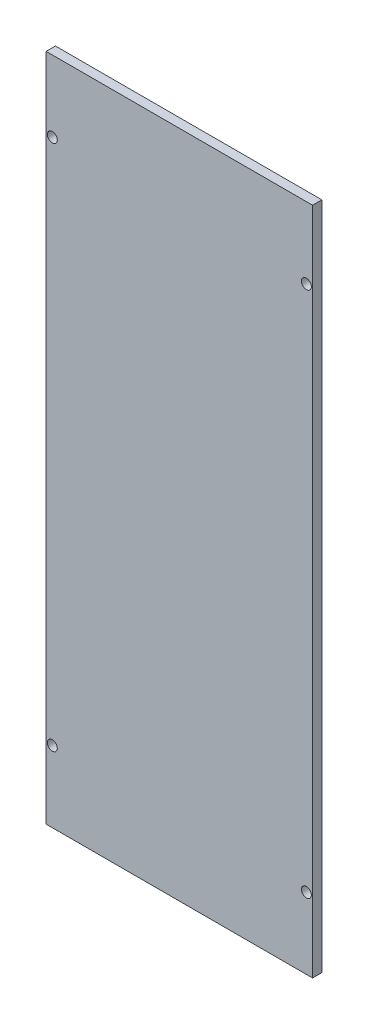
from build123d import *

# Parameters (mm, degrees)
SKETCH_1_W          = 86
SKETCH_1_H          = 216
EXTRUDE_1_DEPTH     = 3
SKETCH_2_R          = 1.6
CUT_EXTRUDE_1_DEPTH = 3


with BuildPart() as part:
    # 草图1 → 凸台-拉伸1 (new body)
    with BuildSketch(Plane.XY):
        with Locations((43, 108)):
            Rectangle(SKETCH_1_W, SKETCH_1_H)
    extrude(amount=EXTRUDE_1_DEPTH)

    # 草图2 → 切除-拉伸1 (cut)
    with BuildSketch(Plane.XY.offset(3)):
        with Locations((2, 193)):
            Circle(SKETCH_2_R)
        with Locations((2, 23)):
            Circle(SKETCH_2_R)
        with Locations((84, 23)):
            Circle(SKETCH_2_R)
        with Locations((84, 193)):
            Circle(SKETCH_2_R)
    extrude(amount=-CUT_EXTRUDE_1_DEPTH, mode=Mode.SUBTRACT)


solid = part.part
